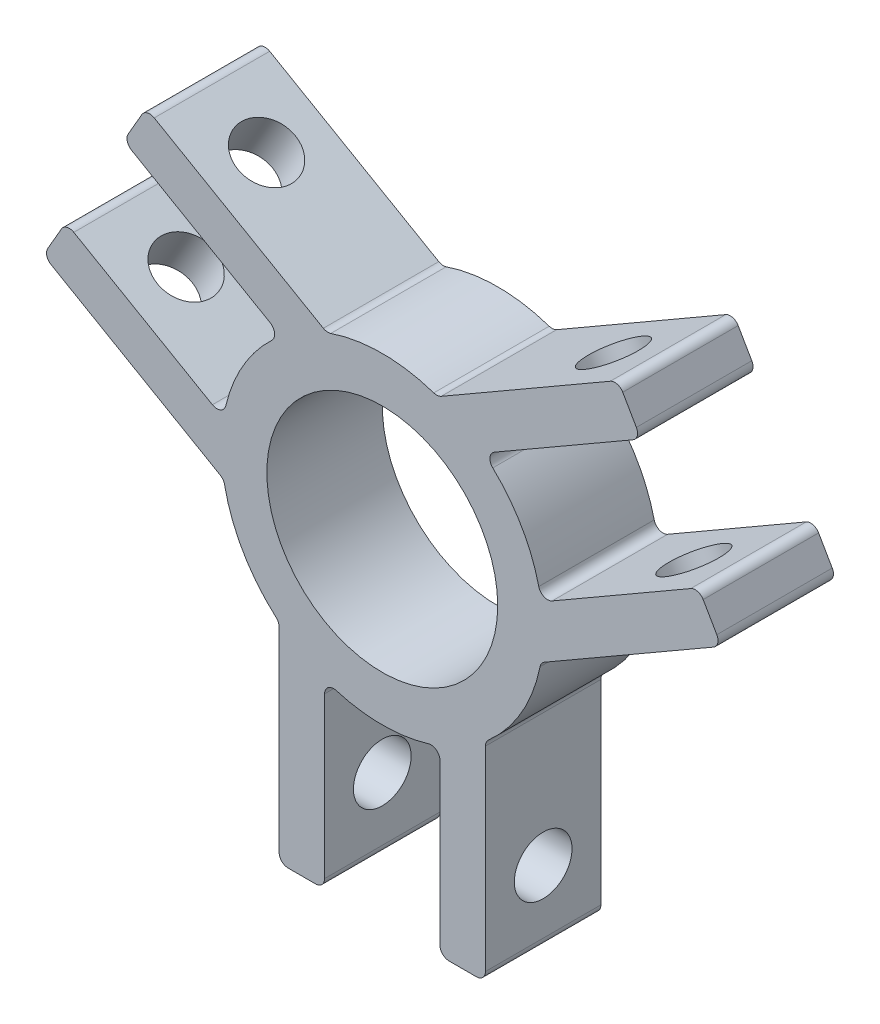
from build123d import *

# Parameters (mm, degrees)
ESQUISSE1_R             = 17.7
ESQUISSE1_R_2           = 12.7
BOSS_EXTRU_1_DEPTH      = 12.7
BOSS_EXTRU_2_DEPTH      = 12.7
ESQUISSE3_R             = 3.175
ENL_V_MAT_EXTRU_1_DEPTH = 62.63061651
ESQUISSE4_R             = 3.175
ENL_V_MAT_EXTRU_2_DEPTH = 62.63061651
ESQUISSE5_R             = 3.175
ENL_V_MAT_EXTRU_3_DEPTH = 49.65374434
CONG_1_R                = 1


with BuildPart() as part:
    # Esquisse1 → Boss.-Extru.1 (new body)
    with BuildSketch(Plane.XY):
        Circle(ESQUISSE1_R)
        Circle(ESQUISSE1_R_2, mode=Mode.SUBTRACT)
    extrude(amount=BOSS_EXTRU_1_DEPTH)

    # Esquisse2 → Boss.-Extru.2 (add)
    with BuildSketch(Plane.XY.offset(12.7)):
        Polygon((28.45374434, 23.760125373), (11.133236264, 13.760125373), (6.087254248, 16.620328989), (25.95374434, 28.090252392), align=None)
        Polygon((17.483236264, 2.761602745), (17.437254248, -3.038447676), (37.30374434, 8.431475726), (34.80374434, 12.761602745), align=None)
        Polygon((11.35, -36.521728118), (11.35, -13.581881313), (6.35, -16.521728118), (6.35, -36.521728118), align=None)
        Polygon((-6.35, -16.521728118), (-11.35, -13.581881313), (-11.35, -36.521728118), (-6.35, -36.521728118), align=None)
        Polygon((-37.30374434, 8.431475726), (-17.437254248, -3.038447676), (-17.483236264, 2.761602745), (-34.80374434, 12.761602745), align=None)
        Polygon((-11.133236264, 13.760125373), (-6.087254248, 16.620328989), (-25.95374434, 28.090252392), (-28.45374434, 23.760125373), align=None)
    extrude(amount=-BOSS_EXTRU_2_DEPTH)

    # Esquisse3 → Enlèv. mat.-Extru.1 (cut, through all)
    with BuildSketch(Plane(origin=(5.675, 9.829388333, 0), x_dir=(0.866025404, -0.5, 0), z_dir=(0.5, 0.866025404, 0))):
        with Locations((-28.584228118, -6.35)):
            Circle(ESQUISSE3_R)
    extrude(amount=-ENL_V_MAT_EXTRU_1_DEPTH, mode=Mode.SUBTRACT)

    # Esquisse4 → Enlèv. mat.-Extru.2 (cut, through all)
    with BuildSketch(Plane(origin=(-5.675, 9.829388333, 0), x_dir=(0.866025404, 0.5, 0), z_dir=(-0.5, 0.866025404, 0))):
        with Locations((28.584228118, -6.35)):
            Circle(ESQUISSE4_R)
    extrude(amount=-ENL_V_MAT_EXTRU_2_DEPTH, mode=Mode.SUBTRACT)

    # Esquisse5 → Enlèv. mat.-Extru.3 (cut, through all)
    with BuildSketch(Plane(origin=(11.35, 0, 0), x_dir=(0, 0, -1), z_dir=(1, 0, 0))):
        with Locations((-6.35, -28.584228118)):
            Circle(ESQUISSE5_R)
    extrude(amount=-ENL_V_MAT_EXTRU_3_DEPTH, mode=Mode.SUBTRACT)

    # Congé1
    cong_1_edges = [part.edges().sort_by_distance(p)[0] for p in [
        (25.95374434, 28.090252392, 6.35),
        (28.45374434, 23.760125373, 6.35),
        (11.133236264, 13.760125373, 6.35),
        (6.087254248, 16.620328989, 6.35),
        (17.483236264, 2.761602745, 6.35),
        (34.80374434, 12.761602745, 6.35),
        (37.30374434, 8.431475726, 6.35),
        (17.437254248, -3.038447676, 6.35),
        (11.35, -36.521728118, 6.35),
        (6.35, -36.521728118, 6.35),
        (6.35, -16.521728118, 6.35),
        (11.35, -13.581881313, 6.35),
        (-6.35, -16.521728118, 6.35),
        (-6.35, -36.521728118, 6.35),
        (-11.35, -36.521728118, 6.35),
        (-11.35, -13.581881313, 6.35),
        (-37.30374434, 8.431475726, 6.35),
        (-34.80374434, 12.761602745, 6.35),
        (-17.483236264, 2.761602745, 6.35),
        (-17.437254248, -3.038447676, 6.35),
        (-11.133236264, 13.760125373, 6.35),
        (-28.45374434, 23.760125373, 6.35),
        (-25.95374434, 28.090252392, 6.35),
        (-6.087254248, 16.620328989, 6.35),
    ]]
    fillet(cong_1_edges, radius=CONG_1_R)


solid = part.part
